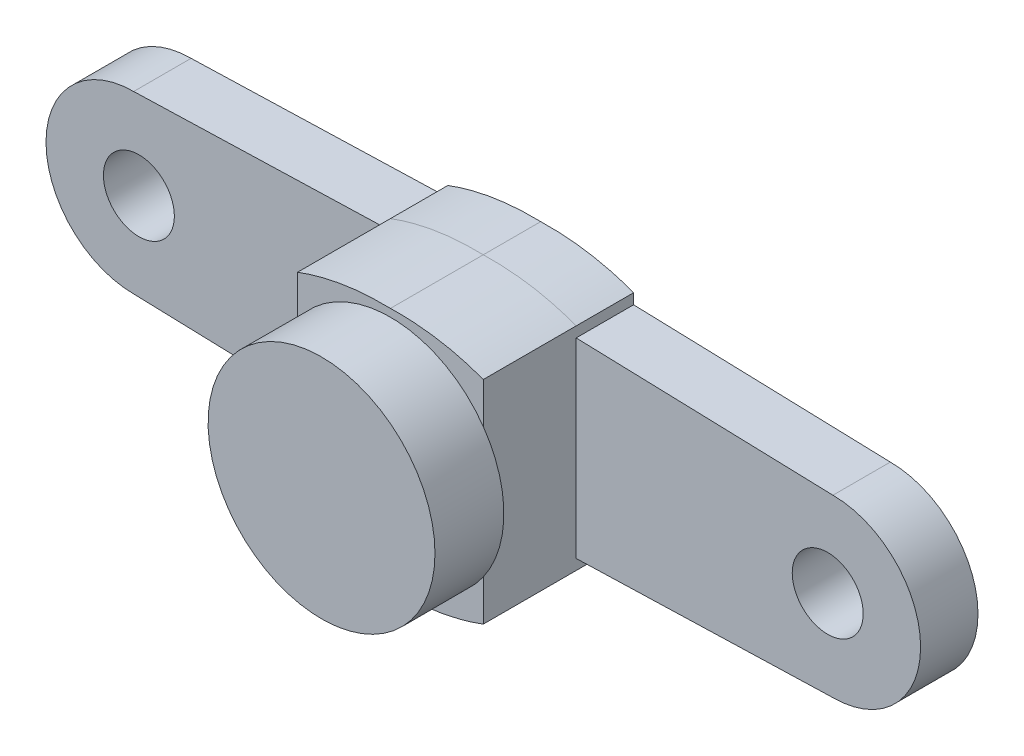
from build123d import *

# Parameters (mm, degrees)
BOSS_EXTRUDE1_DEPTH = 2.75
SKETCH3_R           = 1.7
CUT_EXTRUDE1_DEPTH  = 2.75
BOSS_EXTRUDE2_DEPTH = 4.45
SKETCH6_R           = 5.435
BOSS_EXTRUDE3_DEPTH = 3.3


with BuildPart() as part:
    # Sketch2 → Boss-Extrude1 (new body)
    with BuildSketch(Plane.XY):
        with BuildLine():
            add(Edge.make_bspline(
                [(4.61101002, 8.44423368), (6.970103918, 8.506940606), (9.06101002, 7.719664696)],
                knots=[0, 0, 0, 0.687711527, 0.687711527, 0.687711527], degree=2))
            Line((9.06101002, 7.719664696), (9.06101002, 7.219432127))
            Line((9.06101002, 7.219432127), (21.36101002, 6.84423368))
            ThreePointArc((21.36101002, 6.84423368), (25.56101002, 2.64423368), (21.36101002, -1.55576632))
            Line((21.36101002, -1.55576632), (9.06101002, -1.930964768))
            Line((9.06101002, -1.930964768), (9.06101002, -2.431197337))
            add(Edge.make_bspline(
                [(4.61101002, -3.15576632), (6.970103918, -3.218473247), (9.06101002, -2.431197337)],
                knots=[0, 0, 0, 0.687711527, 0.687711527, 0.687711527], degree=2))
            add(Edge.make_bspline(
                [(4.61101002, -3.15576632), (2.251916122, -3.218473247), (0.16101002, -2.431197337)],
                knots=[0, 0, 0, 0.687711527, 0.687711527, 0.687711527], degree=2))
            Line((0.16101002, -2.431197337), (0.16101002, -1.930964768))
            Line((0.16101002, -1.930964768), (-12.13898998, -1.55576632))
            ThreePointArc((-12.13898998, -1.55576632), (-16.33898998, 2.64423368), (-12.13898998, 6.84423368))
            Line((-12.13898998, 6.84423368), (0.16101002, 7.219432127))
            Line((0.16101002, 7.219432127), (0.16101002, 7.719664696))
            add(Edge.make_bspline(
                [(4.61101002, 8.44423368), (2.251916122, 8.506940606), (0.16101002, 7.719664696)],
                knots=[0, 0, 0, 0.687711527, 0.687711527, 0.687711527], degree=2))
        make_face()
    extrude(amount=BOSS_EXTRUDE1_DEPTH)

    # Sketch3 → Cut-Extrude1 (cut)
    with BuildSketch(Plane.XY.offset(2.75)):
        with Locations((-11.88898998, 2.645532794)):
            Circle(SKETCH3_R)
        with Locations(Location((21.11101002, 2.645532794, 0), (0, 0, 180))):
            Circle(SKETCH3_R)
    extrude(amount=-CUT_EXTRUDE1_DEPTH, mode=Mode.SUBTRACT)

    # Sketch5 → Boss-Extrude2 (add)
    with BuildSketch(Plane.XY.offset(2.75)):
        with BuildLine():
            Line((9.06101002, 7.719664696), (9.06101002, 7.219432127))
            Line((9.06101002, 7.219432127), (9.06101002, -1.930964768))
            Line((9.06101002, -1.930964768), (9.06101002, -2.431197337))
            add(Edge.make_bspline(
                [(4.61101002, -3.15576632), (6.970103918, -3.218473247), (9.06101002, -2.431197337)],
                knots=[0, 0, 0, 1, 1, 1], degree=2))
            add(Edge.make_bspline(
                [(4.61101002, -3.15576632), (2.251916122, -3.218473247), (0.16101002, -2.431197337)],
                knots=[0, 0, 0, 1, 1, 1], degree=2))
            Line((0.16101002, -2.431197337), (0.16101002, -1.930964768))
            Line((0.16101002, -1.930964768), (0.16101002, 7.219432127))
            Line((0.16101002, 7.219432127), (0.16101002, 7.719664696))
            add(Edge.make_bspline(
                [(4.61101002, 8.44423368), (2.251916122, 8.506940606), (0.16101002, 7.719664696)],
                knots=[0, 0, 0, 1, 1, 1], degree=2))
            add(Edge.make_bspline(
                [(4.61101002, 8.44423368), (6.970103918, 8.506940606), (9.06101002, 7.719664696)],
                knots=[0, 0, 0, 1, 1, 1], degree=2))
        make_face()
    extrude(amount=BOSS_EXTRUDE2_DEPTH)

    # Sketch6 → Boss-Extrude3 (add)
    with BuildSketch(Plane.XY.offset(7.2)):
        with Locations(Location((4.611010009, 2.647143575, 0), (0, 0, 215.038419813))):
            Circle(SKETCH6_R)
    extrude(amount=BOSS_EXTRUDE3_DEPTH)


solid = part.part
